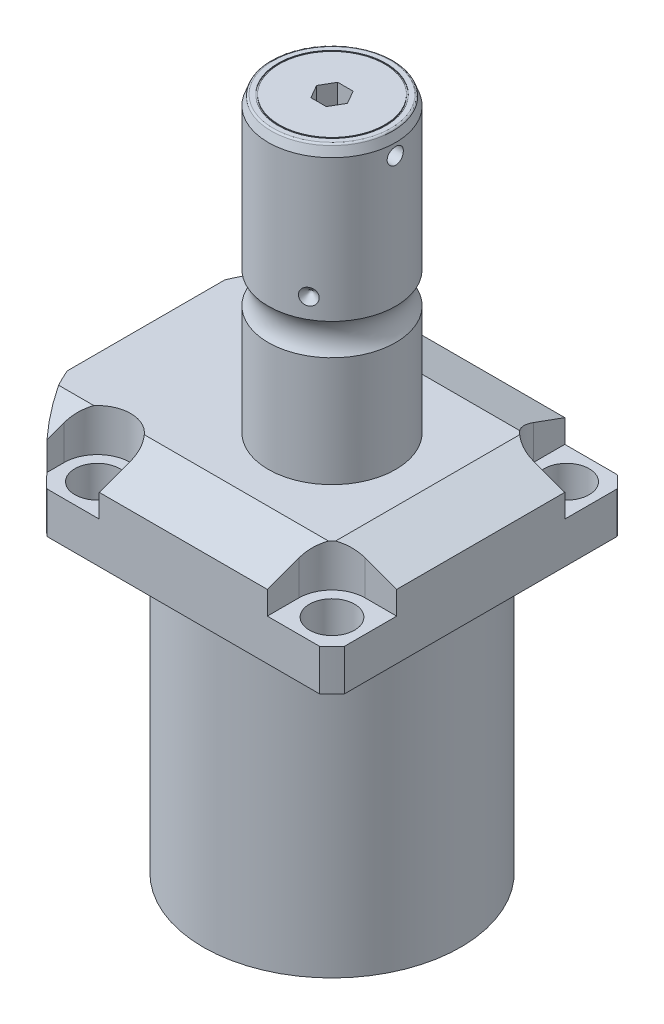
from build123d import *

# Parameters (mm, degrees)
SKETCH1_W               = 88.9
SKETCH1_H               = 99.9998
EXTRUDE1_DEPTH          = 113.919
SKETCH2_OUTSIDE_W       = 137.146
SKETCH2_OUTSIDE_H       = 126.046
SKETCH2_OUTSIDE_R       = 60.325
CUT_EXTRUDE1_DEPTH      = 114.919
SKETCH3_W               = 38.1
SKETCH3_H               = 88.9
FILLET1_R               = 0.381
CUT_EXTRUDE2_DEPTH      = 12.7
CUT_EXTRUDE9_START      = -56.5498
CUT_EXTRUDE9_DEPTH      = 101.9998
CUT_EXTRUDE7_DEPTH      = 45.45
CUT_EXTRUDE7_DEPTH_BACK = 45.45
SKETCH10_R              = 1.1811
SKETCH11_R              = 1.1811
SKETCH14_R              = 7.112
EXTRUDE2_DEPTH          = 1.27
SKETCH17_W              = 6.7437
SKETCH17_H              = 12.319
HOLE1_AT_2_COUNT        = 2
HOLE1_AT_2_PITCH        = 70.104
HOLE1_AT_3_COUNT        = 2
HOLE1_AT_3_PITCH        = 99.142027577
HOLE1_AT_4_COUNT        = 2
HOLE1_AT_4_PITCH        = 70.104
CHAMFER1_SIZE           = 0.635
FILLET2_R               = 0.635
SKETCH21_R              = 16.129
SKETCH21_R_2            = 15.748
CUT_EXTRUDE10_DEPTH     = 0.254
CUT_EXTRUDE11_DEPTH     = 7.9756
CIRPATTERN1_COUNT       = 3
SKETCH24_W              = 3.81
SKETCH24_H              = 2.413


with BuildPart() as part:
    # Sketch1 → Extrude1 (new body)
    with BuildSketch(Plane.ZX):
        with Locations((0, -5.5499)):
            Rectangle(SKETCH1_W, SKETCH1_H)
    extrude(amount=EXTRUDE1_DEPTH)

    # Sketch2 outside → Cut-Extrude1 (cut, through all)
    with BuildSketch(Plane.XZ):
        with Locations((-5.55, 0)):
            Rectangle(SKETCH2_OUTSIDE_W, SKETCH2_OUTSIDE_H)
        Circle(SKETCH2_OUTSIDE_R, mode=Mode.SUBTRACT)
    extrude(amount=-CUT_EXTRUDE1_DEPTH, mode=Mode.SUBTRACT)

    # Sketch3 → Cut-Revolve1 (revolve, cut)
    with BuildSketch(Plane(origin=(0, 0, 0), x_dir=(0, 0, 1), z_dir=(1, 0, 0))):
        with Locations((57.5437, -44.45)):
            Rectangle(SKETCH3_W, SKETCH3_H)
    revolve(axis=Axis((0, 93.345, 0), (0, -1, 0)), mode=Mode.SUBTRACT)

    # Fillet1
    fillet1_edges = [part.edges().sort_by_distance(p)[0] for p in [
        (0, 88.9, -38.4937),
    ]]
    fillet(fillet1_edges, radius=FILLET1_R)

    # Sketch4 → Cut-Extrude2 (cut)
    with BuildSketch(Plane(origin=(0, 113.919, 0), x_dir=(-1, 0, 0), z_dir=(0, 1, 0))):
        with BuildLine():
            Line((-25.1206, -44.45), (-25.1206, -35.052))
            ThreePointArc((-25.1206, -35.052), (-28.029439713, -28.029439713), (-35.052, -25.1206))
            Line((-35.052, -25.1206), (-44.45, -25.1206))
            Line((-44.45, -25.1206), (-44.45, -44.45))
            Line((-44.45, -44.45), (-25.1206, -44.45))
        make_face()
        with BuildLine():
            Line((44.9834, -44.45), (25.1206, -44.45))
            Line((25.1206, -44.45), (25.1206, -35.052))
            ThreePointArc((25.1206, -35.052), (35.052, -25.1206), (44.9834, -35.052))
            Line((44.9834, -35.052), (44.9834, -44.45))
        make_face()
        with BuildLine():
            Line((25.1206, 44.45), (25.1206, 35.052))
            ThreePointArc((25.1206, 35.052), (35.052, 25.1206), (44.9834, 35.052))
            Line((44.9834, 35.052), (44.9834, 44.45))
            Line((44.9834, 44.45), (25.1206, 44.45))
        make_face()
        with BuildLine():
            Line((-35.052, 25.1206), (-44.45, 25.1206))
            Line((-44.45, 25.1206), (-44.45, 44.45))
            Line((-44.45, 44.45), (-25.1206, 44.45))
            Line((-25.1206, 44.45), (-25.1206, 35.052))
            ThreePointArc((-25.1206, 35.052), (-28.029439713, 28.029439713), (-35.052, 25.1206))
        make_face()
    extrude(amount=-CUT_EXTRUDE2_DEPTH, mode=Mode.SUBTRACT)

    # Sketch5 → Cut-Extrude9 (cut)
    with BuildSketch(Plane(origin=(0, 0, 0), x_dir=(0, 0, -1), z_dir=(1, 0, 0)).offset(CUT_EXTRUDE9_START)):
        Polygon((-28.575, 113.919), (-44.45, 108.140972531), (-44.45, 113.919), align=None)
    cut_extrude9 = extrude(amount=CUT_EXTRUDE9_DEPTH, mode=Mode.SUBTRACT)

    # Mirror1: Cut-Extrude9 across plane
    add(cut_extrude9.mirror(Plane.XY), mode=Mode.SUBTRACT)

    # Sketch9 → Cut-Extrude7 (cut, two sides)
    with BuildSketch(Plane.XY) as cut_extrude7_sk:
        Polygon((28.575, 113.919), (44.45, 108.140972531), (44.45, 113.919), align=None)
    extrude(amount=CUT_EXTRUDE7_DEPTH, mode=Mode.SUBTRACT)
    extrude(cut_extrude7_sk.sketch, amount=-CUT_EXTRUDE7_DEPTH_BACK, mode=Mode.SUBTRACT)

    # Sketch20 → Cut-Revolve4 (revolve, cut)
    with BuildSketch(Plane(origin=(-41.402, 88.9, -18.1102), x_dir=(0, 1, 0), z_dir=(1, 0, 0)), mode=Mode.PRIVATE) as cut_revolve4_sk:
        Polygon((0, 41.9227), (1.4478, 41.9227), (1.4478, 39.4716), (2.4638, 39.4716), (2.4638, 37.465), (13.4366, 37.465), (13.4366, 36.2204), (0, 36.2204), align=None)
    cut_revolve4 = revolve(cut_revolve4_sk.sketch.rotate(Axis((-41.402, 81.620304954, 18.1102), (0, 1, 0)), 180), axis=Axis((-41.402, 81.620304954, 18.1102), (0, 1, 0)), mode=Mode.SUBTRACT)  # turned: the seam where the file's is

    # Mirror10: Cut-Revolve4 across plane
    add(cut_revolve4.mirror(Plane.XY), mode=Mode.SUBTRACT)

    # S2D0007 → Cut-Revolve2 (revolve, cut)
    with BuildSketch(Plane(origin=(-55.5498, 101.9048, 12.9794), x_dir=(0, 1, 0), z_dir=(0, 0, 1)), mode=Mode.PRIVATE) as cut_revolve2_sk:
        Polygon((0, 0), (10.4775, 0), (10.4775, -0.254), (6.1849, -0.254), (5.642306865, -2.8067), (4.9784, -3.470606865), (4.9784, -14.224), (0, -14.224), align=None)
    revolve(cut_revolve2_sk.sketch.rotate(Axis((-40.6146, 101.9048, 12.9794), (-1, 0, 0)), 90), axis=Axis((-40.6146, 101.9048, 12.9794), (-1, 0, 0)), mode=Mode.SUBTRACT)  # turned: the seam where the file's is

    # Sketch13 → Cut-Revolve3 (revolve, cut)
    with BuildSketch(Plane(origin=(-55.5498, 101.9048, -12.9794), x_dir=(0, 1, 0), z_dir=(0, 0, 1)), mode=Mode.PRIVATE) as cut_revolve3_sk:
        Polygon((0, 0), (10.4775, 0), (10.4775, -0.254), (6.1849, -0.254), (5.642306865, -2.8067), (4.9784, -3.470606865), (4.9784, -14.224), (0, -14.224), align=None)
    revolve(cut_revolve3_sk.sketch.rotate(Axis((-40.6146, 101.9048, -12.9794), (-1, 0, 0)), 90), axis=Axis((-40.6146, 101.9048, -12.9794), (-1, 0, 0)), mode=Mode.SUBTRACT)  # turned: the seam where the file's is

    # Sketch14 → Extrude2 (add)
    with BuildSketch(Plane.ZY.offset(55.2958)):
        with Locations(Location((-12.9794, 101.9048, 0), (0, 0, 180))):  # turned: the seam where the file's is
            Circle(SKETCH14_R)
    extrude(amount=EXTRUDE2_DEPTH)

    # Sketch15 → Revolve3 (revolve)
    with BuildSketch(Plane(origin=(0, 0, 0), x_dir=(0, -1, 0), z_dir=(1, 0, 0)), mode=Mode.PRIVATE) as revolve3_sk:
        with BuildLine():
            Line((-113.919, 0), (-113.919, 19.05))
            Line((-113.919, 19.05), (-146.75310643, 19.05))
            ThreePointArc((-146.75310643, 19.05), (-151.4602, 17.5006), (-156.16729357, 19.05))
            Line((-156.16729357, 19.05), (-198.5264, 19.05))
            Line((-198.5264, 19.05), (-201.4474, 17.986842946))
            Line((-201.4474, 17.986842946), (-201.4474, 0))
            Line((-201.4474, 0), (-113.919, 0))
        make_face()
    revolve(revolve3_sk.sketch.rotate(Axis((0, 197.63613, 0), (0, -1, 0)), 180), axis=Axis((0, 197.63613, 0), (0, -1, 0)))  # turned: the seam where the file's is

    # Sketch17 → Hole1 (revolve, cut)
    with BuildSketch(Plane(origin=(35.052, 101.219, -35.052), x_dir=(0, 0, 1), z_dir=(1, 0, 0))):
        with Locations((3.37185, 6.1595)):
            Rectangle(SKETCH17_W, SKETCH17_H)
    hole1 = revolve(axis=Axis((35.052, -8.781, -35.052), (0, 1, 0)), mode=Mode.SUBTRACT)

    # Hole1 at 2: Hole1 ×2
    with Locations(*[(0, 0, i * HOLE1_AT_2_PITCH) for i in range(1, HOLE1_AT_2_COUNT)]):
        add(hole1, mode=Mode.SUBTRACT)

    # Hole1 at 3: Hole1 ×2
    with Locations(*[Vector(-0.707106781, 0, 0.707106781) * (i * HOLE1_AT_3_PITCH) for i in range(1, HOLE1_AT_3_COUNT)]):
        add(hole1, mode=Mode.SUBTRACT)

    # Hole1 at 4: Hole1 ×2
    with Locations(*[(-i * HOLE1_AT_4_PITCH, 0, 0) for i in range(1, HOLE1_AT_4_COUNT)]):
        add(hole1, mode=Mode.SUBTRACT)

    # Chamfer1
    chamfer1_edges = [part.edges().sort_by_distance(p)[0] for p in [
        (-41.402, 91.3638, 19.3548),
        (-41.402, 91.3638, -19.3548),
    ]]
    chamfer(chamfer1_edges, length=CHAMFER1_SIZE)

    # Fillet2
    fillet2_edges = [part.edges().sort_by_distance(p)[0] for p in [
        (0, 201.4474, -17.986842946),
    ]]
    fillet(fillet2_edges, radius=FILLET2_R)

    # Sketch21 → Cut-Extrude10 (cut)
    with BuildSketch(Plane(origin=(0, 201.4474, 0), x_dir=(1, 0, 0), z_dir=(0, 1, 0))):
        with Locations(Location((0, 0, 0), (0, 0, 270))):  # turned: the seam where the file's is
            Circle(SKETCH21_R)
        with Locations(Location((0, 0, 0), (0, 0, 270))):  # turned: the seam where the file's is
            Circle(SKETCH21_R_2, mode=Mode.SUBTRACT)
    extrude(amount=-CUT_EXTRUDE10_DEPTH, mode=Mode.SUBTRACT)

    # Sketch22 → Cut-Extrude11 (cut)
    with BuildSketch(Plane(origin=(0, 201.4474, 0), x_dir=(1, 0, 0), z_dir=(0, 1, 0))):
        Polygon((4.618792916, 0), (2.309396458, 3.999992), (-2.309396458, 3.999992), (-4.618792916, 0), (-2.309396458, -3.999992), (2.309396458, -3.999992), align=None)
    extrude(amount=-CUT_EXTRUDE11_DEPTH, mode=Mode.SUBTRACT)

    # Sketch23 → Cut-Revolve5 (revolve, cut)
    with BuildSketch(Plane.XY, mode=Mode.PRIVATE) as cut_revolve5_sk:
        Polygon((-19.05, 164.5412), (-16.637, 162.1282), (-19.05, 162.1282), align=None)
    cut_revolve5 = revolve(cut_revolve5_sk.sketch.rotate(Axis((7.837338217, 162.1282, 0), (-1, 0, 0)), 270), axis=Axis((7.837338217, 162.1282, 0), (-1, 0, 0)), mode=Mode.SUBTRACT)  # turned: the seam where the file's is

    # CirPattern1: Cut-Revolve5 ×3 about axis
    cirpattern1_axis = Axis((0, 197.63613, 0), (0, 1, 0))
    for i in range(1, CIRPATTERN1_COUNT):
        add(cut_revolve5.rotate(cirpattern1_axis, i * 360 / CIRPATTERN1_COUNT), mode=Mode.SUBTRACT)

    # Sketch24 → Cut-Revolve6 (revolve, cut)
    with BuildSketch(Plane.XY, mode=Mode.PRIVATE) as cut_revolve6_sk:
        with Locations((17.145, 196.3039)):
            Rectangle(SKETCH24_W, SKETCH24_H)
    revolve(cut_revolve6_sk.sketch.rotate(Axis((3.251219244, 195.0974, 0), (1, 0, 0)), 90), axis=Axis((3.251219244, 195.0974, 0), (1, 0, 0)), mode=Mode.SUBTRACT)  # turned: the seam where the file's is


with BuildPart() as body_2:
    # Sketch10 → Revolve4 (revolve)
    with BuildSketch(Plane(origin=(-41.402, 88.9, -18.1102), x_dir=(0, 1, 0), z_dir=(1, 0, 0))):
        with Locations((0.2667, 4.5212)):
            Circle(SKETCH10_R)
    revolve(axis=Axis((-41.402, 87.86749, -18.1102), (0, 1, 0)))


with BuildPart() as body_3:
    # Sketch11 → Revolve2 (revolve)
    with BuildSketch(Plane(origin=(-41.402, 88.9, 18.1102), x_dir=(0, 1, 0), z_dir=(1, 0, 0)), mode=Mode.PRIVATE) as revolve2_sk:
        with Locations((0.2667, 4.5212)):
            Circle(SKETCH11_R)
    revolve(revolve2_sk.sketch.rotate(Axis((-41.402, 87.86749, 18.1102), (0, 1, 0)), 180), axis=Axis((-41.402, 87.86749, 18.1102), (0, 1, 0)))  # turned: the seam where the file's is


solid = Compound([part.part, body_2.part, body_3.part])
